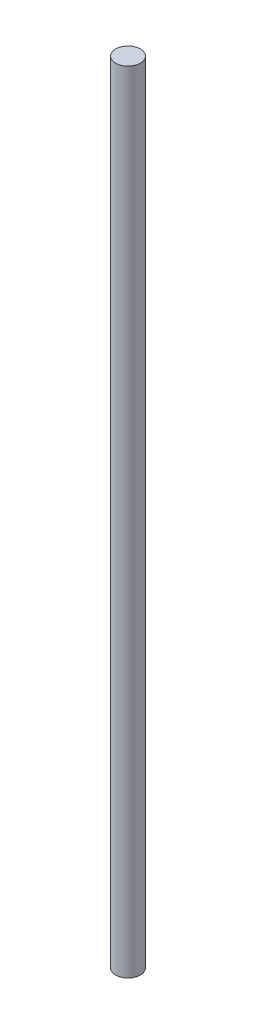
from build123d import *

# Parameters (mm, degrees)
SKETCH1_R           = 3.175
BOSS_EXTRUDE1_DEPTH = 203.2


with BuildPart() as part:
    # Sketch1 → Boss-Extrude1 (new body)
    with BuildSketch(Plane(origin=(0, 0, 0), x_dir=(1, 0, 0), z_dir=(0, 1, 0))):
        Circle(SKETCH1_R)
    extrude(amount=BOSS_EXTRUDE1_DEPTH)


solid = part.part
